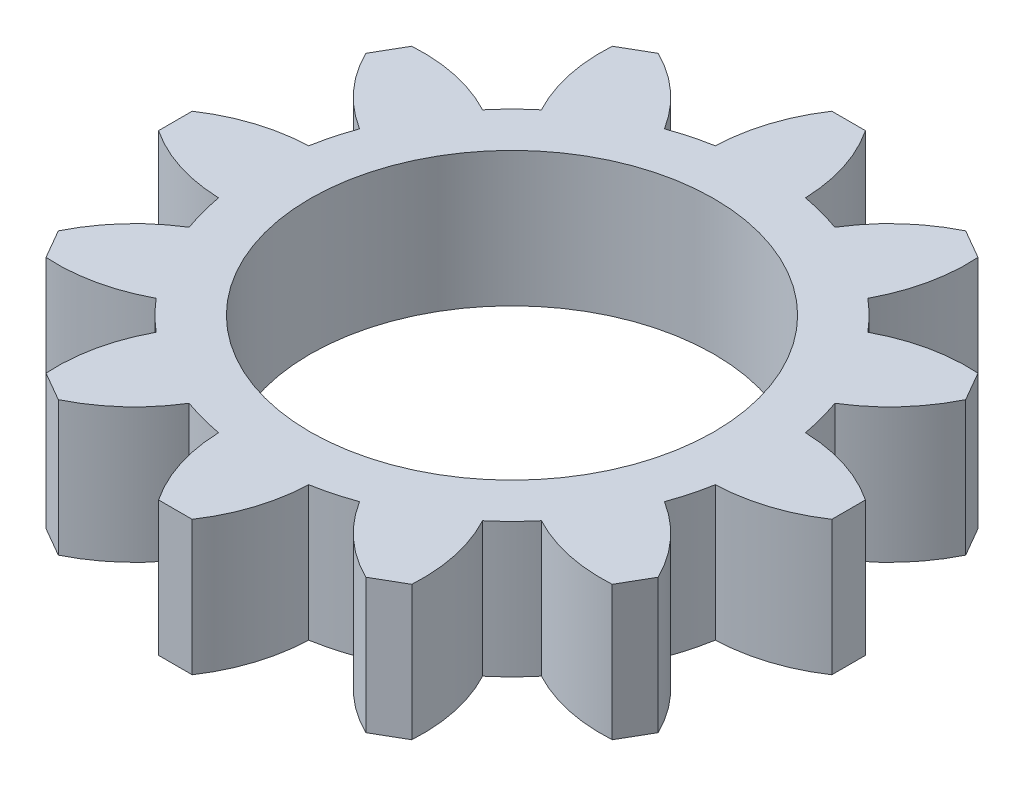
from build123d import *

# Parameters (mm, degrees)
SKETCH1_R           = 12
BOSS_EXTRUDE1_DEPTH = 4


with BuildPart() as part:
    # Sketch1 → Boss-Extrude1 (new body, symmetric)
    with BuildSketch(Plane(origin=(0, 0, 0), x_dir=(1, 0, 0), z_dir=(0, 1, 0))):
        with BuildLine():
            Line((-1, 20), (1, 20))
            ThreePointArc((1, 20), (2.204975942, 17.497232023), (2.675, 14.759551992))
            ThreePointArc((2.675, 14.759551992), (3.882285677, 14.488887394), (5.063158041, 14.119646973))
            ThreePointArc((5.063158041, 14.119646973), (6.839050831, 16.255535399), (9.133974596, 17.820508076))
            Line((9.133974596, 17.820508076), (10.866025404, 16.820508076))
            ThreePointArc((10.866025404, 16.820508076), (10.658181192, 14.050559457), (9.696393951, 11.444646973))
            ThreePointArc((9.696393951, 11.444646973), (10.606601718, 10.606601718), (11.444646973, 9.696393951))
            ThreePointArc((11.444646973, 9.696393951), (14.050559457, 10.658181192), (16.820508076, 10.866025404))
            Line((16.820508076, 10.866025404), (17.820508076, 9.133974596))
            ThreePointArc((17.820508076, 9.133974596), (16.255535399, 6.839050831), (14.119646973, 5.063158041))
            ThreePointArc((14.119646973, 5.063158041), (14.488887394, 3.882285677), (14.759551992, 2.675))
            ThreePointArc((14.759551992, 2.675), (17.497232023, 2.204975942), (20, 1))
            Line((20, 1), (20, -1))
            ThreePointArc((20, -1), (17.497232023, -2.204975942), (14.759551992, -2.675))
            ThreePointArc((14.759551992, -2.675), (14.488887394, -3.882285677), (14.119646973, -5.063158041))
            ThreePointArc((14.119646973, -5.063158041), (16.255535399, -6.839050831), (17.820508076, -9.133974596))
            Line((17.820508076, -9.133974596), (16.820508076, -10.866025404))
            ThreePointArc((16.820508076, -10.866025404), (14.050559457, -10.658181192), (11.444646973, -9.696393951))
            ThreePointArc((11.444646973, -9.696393951), (10.606601718, -10.606601718), (9.696393951, -11.444646973))
            ThreePointArc((9.696393951, -11.444646973), (10.658181192, -14.050559457), (10.866025404, -16.820508076))
            Line((10.866025404, -16.820508076), (9.133974596, -17.820508076))
            ThreePointArc((9.133974596, -17.820508076), (6.839050831, -16.255535399), (5.063158041, -14.119646973))
            ThreePointArc((5.063158041, -14.119646973), (3.882285677, -14.488887394), (2.675, -14.759551992))
            ThreePointArc((2.675, -14.759551992), (2.204975942, -17.497232023), (1, -20))
            Line((1, -20), (-1, -20))
            ThreePointArc((-1, -20), (-2.204975942, -17.497232023), (-2.675, -14.759551992))
            ThreePointArc((-2.675, -14.759551992), (-3.882285677, -14.488887394), (-5.063158041, -14.119646973))
            ThreePointArc((-5.063158041, -14.119646973), (-6.839050831, -16.255535399), (-9.133974596, -17.820508076))
            Line((-9.133974596, -17.820508076), (-10.866025404, -16.820508076))
            ThreePointArc((-10.866025404, -16.820508076), (-10.658181192, -14.050559457), (-9.696393951, -11.444646973))
            ThreePointArc((-9.696393951, -11.444646973), (-10.606601718, -10.606601718), (-11.444646973, -9.696393951))
            ThreePointArc((-11.444646973, -9.696393951), (-14.050559457, -10.658181192), (-16.820508076, -10.866025404))
            Line((-16.820508076, -10.866025404), (-17.820508076, -9.133974596))
            ThreePointArc((-17.820508076, -9.133974596), (-16.255535399, -6.839050831), (-14.119646973, -5.063158041))
            ThreePointArc((-14.119646973, -5.063158041), (-14.488887394, -3.882285677), (-14.759551992, -2.675))
            ThreePointArc((-14.759551992, -2.675), (-17.497232023, -2.204975942), (-20, -1))
            Line((-20, -1), (-20, 1))
            ThreePointArc((-20, 1), (-17.497232023, 2.204975942), (-14.759551992, 2.675))
            ThreePointArc((-14.759551992, 2.675), (-14.488887394, 3.882285677), (-14.119646973, 5.063158041))
            ThreePointArc((-14.119646973, 5.063158041), (-16.255535399, 6.839050831), (-17.820508076, 9.133974596))
            Line((-17.820508076, 9.133974596), (-16.820508076, 10.866025404))
            ThreePointArc((-16.820508076, 10.866025404), (-14.050559457, 10.658181192), (-11.444646973, 9.696393951))
            ThreePointArc((-11.444646973, 9.696393951), (-10.606601718, 10.606601718), (-9.696393951, 11.444646973))
            ThreePointArc((-9.696393951, 11.444646973), (-10.658181192, 14.050559457), (-10.866025404, 16.820508076))
            Line((-10.866025404, 16.820508076), (-9.133974596, 17.820508076))
            ThreePointArc((-9.133974596, 17.820508076), (-6.839050831, 16.255535399), (-5.063158041, 14.119646973))
            ThreePointArc((-5.063158041, 14.119646973), (-3.882285677, 14.488887394), (-2.675, 14.759551992))
            ThreePointArc((-2.675, 14.759551992), (-2.204975942, 17.497232023), (-1, 20))
        make_face()
        Circle(SKETCH1_R, mode=Mode.SUBTRACT)
    extrude(amount=BOSS_EXTRUDE1_DEPTH, both=True)


solid = part.part
